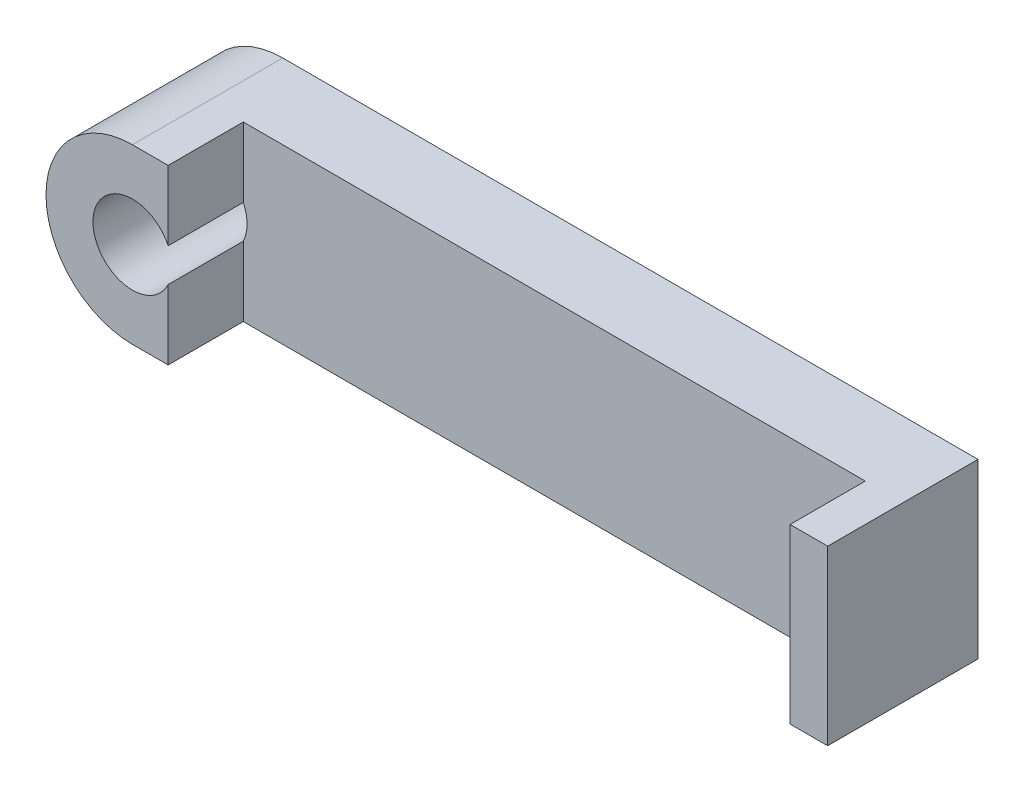
from build123d import *

# Parameters (mm, degrees)
SKETCH2_R           = 2.1
BOSS_EXTRUDE2_DEPTH = 4
SKETCH3_W           = 2
SKETCH3_H           = 9.2
BOSS_EXTRUDE3_DEPTH = 4


with BuildPart() as part:
    # Sketch2 → Boss-Extrude2 (new body)
    with BuildSketch(Plane.XY):
        with BuildLine():
            Line((0, 4.6), (37, 4.6))
            Line((37, 4.6), (37, -4.6))
            Line((37, -4.6), (0, -4.6))
            ThreePointArc((0, -4.6), (-4.6, 0), (0, 4.6))
        make_face()
        Circle(SKETCH2_R, mode=Mode.SUBTRACT)
    extrude(amount=BOSS_EXTRUDE2_DEPTH)

    # Sketch3 → Boss-Extrude3 (add)
    with BuildSketch(Plane.XY.offset(4)):
        with Locations((36, 0)):
            Rectangle(SKETCH3_W, SKETCH3_H)
        with BuildLine():
            Line((1.9, 4.6), (1.9, 0.894427191))
            ThreePointArc((1.9, 0.894427191), (-2.1, 0), (1.9, -0.894427191))
            Line((1.9, -0.894427191), (1.9, -4.6))
            Line((1.9, -4.6), (0, -4.6))
            ThreePointArc((0, -4.6), (-4.6, 0), (0, 4.6))
            Line((0, 4.6), (1.9, 4.6))
        make_face()
    extrude(amount=BOSS_EXTRUDE3_DEPTH)


solid = part.part
